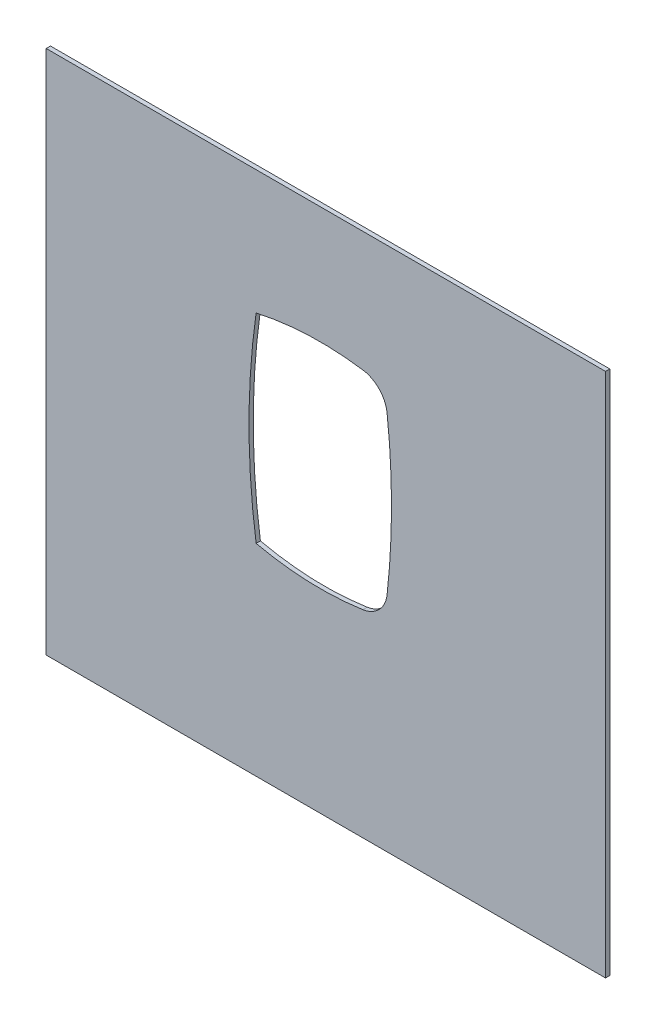
from build123d import *

# Parameters (mm, degrees)
SKIZZE1_W                       = 392.409898916
SKIZZE1_H                       = 368.579338253
AUFSATZ_LINEAR_AUSTRAGEN1_DEPTH = 3


with BuildPart() as part:
    # Skizze1 → Aufsatz-Linear austragen1 (new body)
    with BuildSketch(Plane.XY):
        with Locations((3.931385317, -27.213089131)):
            Rectangle(SKIZZE1_W, SKIZZE1_H)
        with BuildLine():
            ThreePointArc((29.936886891, 72.802324452), (-7.660783232, 74.856809504), (-45, 70))
            ThreePointArc((-45, 70), (-50, 0), (-45, -70))
            ThreePointArc((-45, -70), (-7.660783232, -74.856809504), (29.936886891, -72.802324452))
            ThreePointArc((29.936886891, -72.802324452), (41.39751926, -66.915583853), (46.889917221, -55.260826292))
            ThreePointArc((46.889917221, -55.260826292), (50, 0), (46.889917221, 55.260826292))
            ThreePointArc((46.889917221, 55.260826292), (41.39751926, 66.915583853), (29.936886891, 72.802324452))
        make_face(mode=Mode.SUBTRACT)
    extrude(amount=AUFSATZ_LINEAR_AUSTRAGEN1_DEPTH)


solid = part.part
